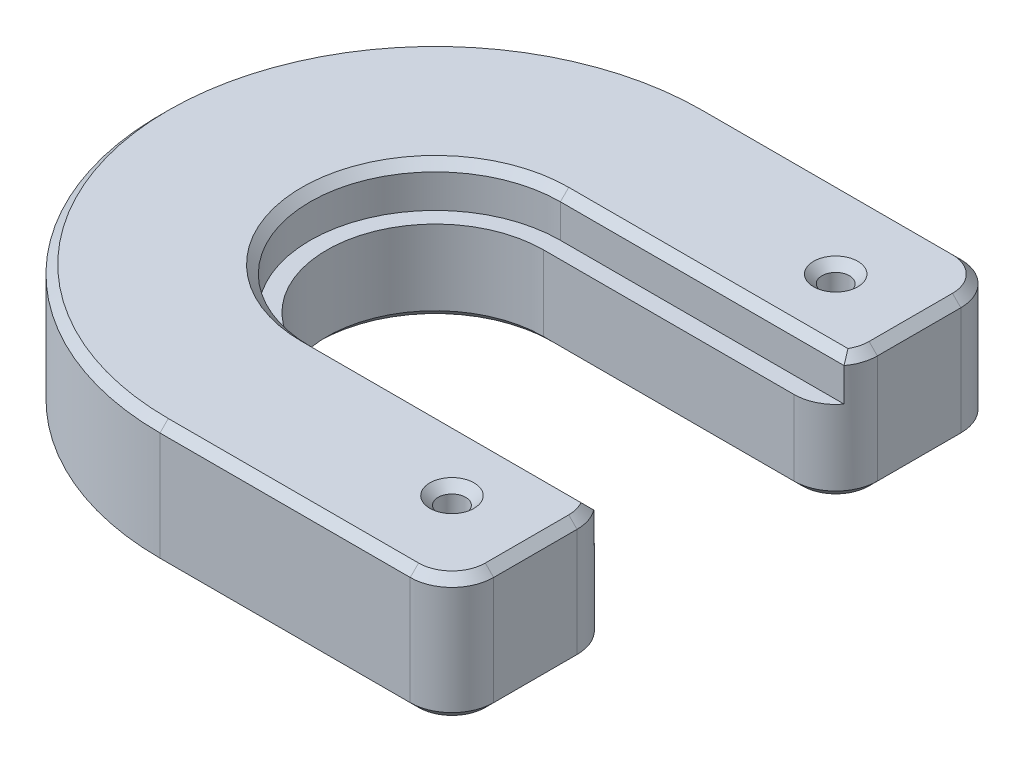
from build123d import *

# Parameters (mm, degrees)
BOSS_EXTRUDE1_DEPTH = 10
BOSS_EXTRUDE3_DEPTH = 5
FILLET1_R           = 5
SKETCH5_R           = 1.65
CUT_EXTRUDE2_DEPTH  = 20
CHAMFER1_SIZE       = 1


with BuildPart() as part:
    # Sketch1 → Boss-Extrude1 (new body)
    with BuildSketch(Plane(origin=(0, 0, 0), x_dir=(1, 0, 0), z_dir=(0, 1, 0))):
        with BuildLine():
            Line((0, 33), (35, 33))
            Line((35, 33), (35, 13))
            Line((35, 13), (0, 13))
            ThreePointArc((0, 13), (-13, 0), (0, -13))
            Line((0, -13), (35, -13))
            Line((35, -13), (35, -33))
            Line((35, -33), (0, -33))
            ThreePointArc((0, -33), (-33, 0), (0, 33))
        make_face()
    extrude(amount=BOSS_EXTRUDE1_DEPTH)

    # Sketch4 → Boss-Extrude3 (add)
    with BuildSketch(Plane(origin=(0, 10, 0), x_dir=(1, 0, 0), z_dir=(0, 1, 0))):
        with BuildLine():
            Line((0, 15), (35, 15))
            Line((35, 15), (35, 33))
            Line((35, 33), (0, 33))
            ThreePointArc((0, 33), (-33, 0), (0, -33))
            Line((0, -33), (35, -33))
            Line((35, -33), (35, -15))
            Line((35, -15), (0, -15))
            ThreePointArc((0, -15), (-15, 0), (0, 15))
        make_face()
    extrude(amount=BOSS_EXTRUDE3_DEPTH)

    # Fillet1
    fillet1_edges = [part.edges().sort_by_distance(p)[0] for p in [
        (35, 7.5, -33),
        (35, 5, -13),
        (35, 5, 13),
        (35, 7.5, 33),
    ]]
    fillet(fillet1_edges, radius=FILLET1_R)

    # Sketch5 → Cut-Extrude2 (cut)
    with BuildSketch(Plane(origin=(0, 15, 0), x_dir=(1, 0, 0), z_dir=(0, 1, 0))):
        with Locations((25, 23)):
            Circle(SKETCH5_R)
        with Locations((25, -23)):
            Circle(SKETCH5_R)
    extrude(amount=-CUT_EXTRUDE2_DEPTH, mode=Mode.SUBTRACT)

    # Chamfer1
    chamfer1_edges = [part.edges().sort_by_distance(p)[0] for p in [
        (15, 0, 33),
        (-33, 0, 0),
        (-15, 15, 0),
        (17, 15, -15),
        (-33, 15, 0),
        (15, 15, 33),
        (15, 0, -33),
        (15, 15, -33),
        (35, 0, -23),
        (15, 0, 13),
        (35, 0, 23),
        (33.535533906, 0, 31.535533906),
        (33.535533906, 0, 14.464466094),
        (33.535533906, 0, -14.464466094),
        (33.535533906, 0, -31.535533906),
        (35, 15, -23),
        (35, 15, 23),
        (17, 15, 15),
        (33.535533906, 15, 31.535533906),
        (34.74341649, 15, 16.41886117),
        (34.74341649, 15, -16.41886117),
        (33.535533906, 15, -31.535533906),
        (23.35, 0, -23),
        (23.35, 15, -23),
        (23.35, 0, 23),
        (23.35, 15, 23),
        (15, 0, -13),
        (-13, 0, 0),
    ]]
    chamfer(chamfer1_edges, length=CHAMFER1_SIZE)


solid = part.part
